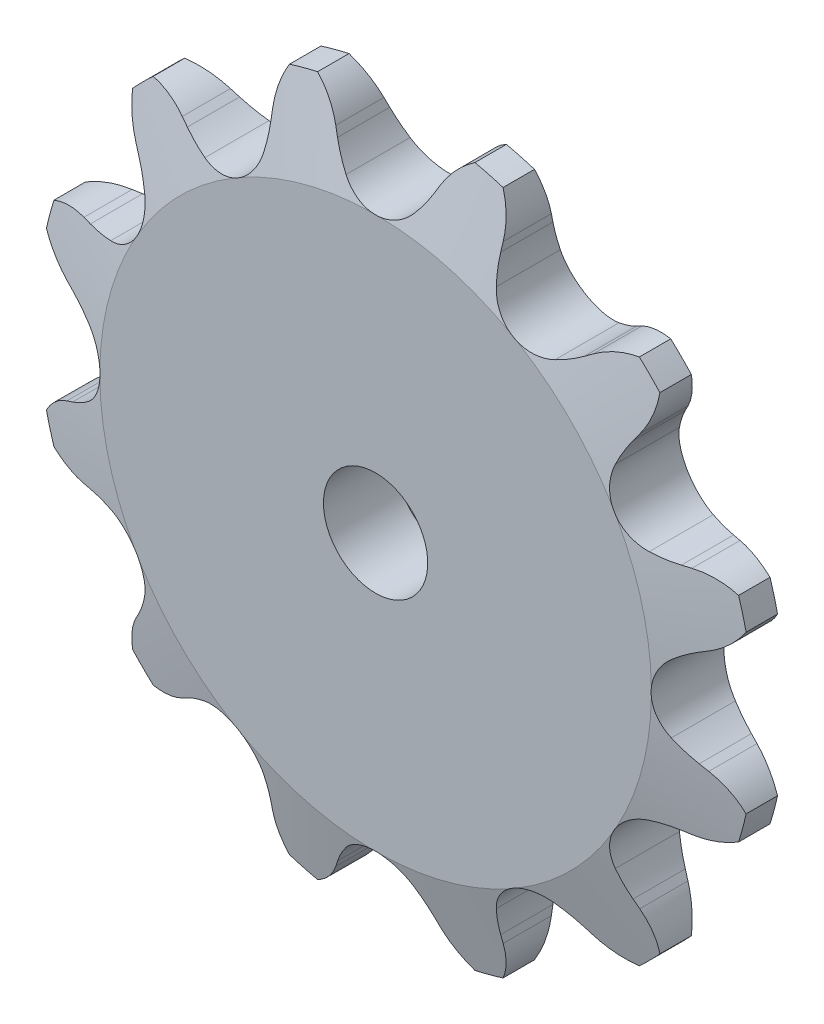
from build123d import *

# Parameters (mm, degrees)
TOOTH_CUT_NUMBER_OF_TEETH_12_DEPTH = 20.501564491
TOOTH_PATTERN_12_12_COUNT          = 12


with BuildPart() as part:
    # Sprocket-BaseSketch → 25 _04C_ ANSI _ISO_ Chain Number_ 0.966i (revolve)
    with BuildSketch(Plane(origin=(0, 0, 0), x_dir=(0, 0, -1), z_dir=(1, 0, 0))):
        Polygon((1.397, 2), (1.397, 10.579261314), (0.60325, 13.754261314), (-0.60325, 13.754261314), (-1.397, 10.579261314), (-1.397, 2), align=None)
    revolve(axis=Axis((0, 0, -5.588), (0, 0, 1)))

    # Tooth-Sketch → Tooth-Cut_ Number of teeth_ 12 (cut, symmetric)
    with BuildSketch(Plane.XY):
        with BuildLine():
            Line((1.853848812, 12.017926297), (1.999985234, 12.308907838))
            ThreePointArc((1.999985234, 12.308907838), (3.017010036, 13.41879565), (4.46528191, 13.829525469))
            ThreePointArc((4.46528191, 13.829525469), (0, 14.532533063), (-4.46528191, 13.829525469))
            ThreePointArc((-4.46528191, 13.829525469), (-3.017010036, 13.41879565), (-1.999985234, 12.308907838))
            Line((-1.999985234, 12.308907838), (-1.853848812, 12.017926297))
            ThreePointArc((-1.853848812, 12.017926297), (-1.601561016, 11.580951016), (-1.300249366, 11.176219231))
            ThreePointArc((-1.300249366, 11.176219231), (0, 10.569902994), (1.300249366, 11.176219231))
            ThreePointArc((1.300249366, 11.176219231), (1.601561016, 11.580951016), (1.853848812, 12.017926297))
        make_face()
    tooth_cut_number_of_teeth_12 = extrude(amount=TOOTH_CUT_NUMBER_OF_TEETH_12_DEPTH, both=True, mode=Mode.SUBTRACT)

    # Tooth Pattern_ 12 _ 12: Tooth-Cut_ Number of teeth_ 12 ×12 about axis
    tooth_pattern_12_12_axis = Axis((0, 0, -88.99), (0, 0, 1))
    for i in range(1, TOOTH_PATTERN_12_12_COUNT):
        add(tooth_cut_number_of_teeth_12.rotate(tooth_pattern_12_12_axis, i * 360 / TOOTH_PATTERN_12_12_COUNT), mode=Mode.SUBTRACT)


solid = part.part
